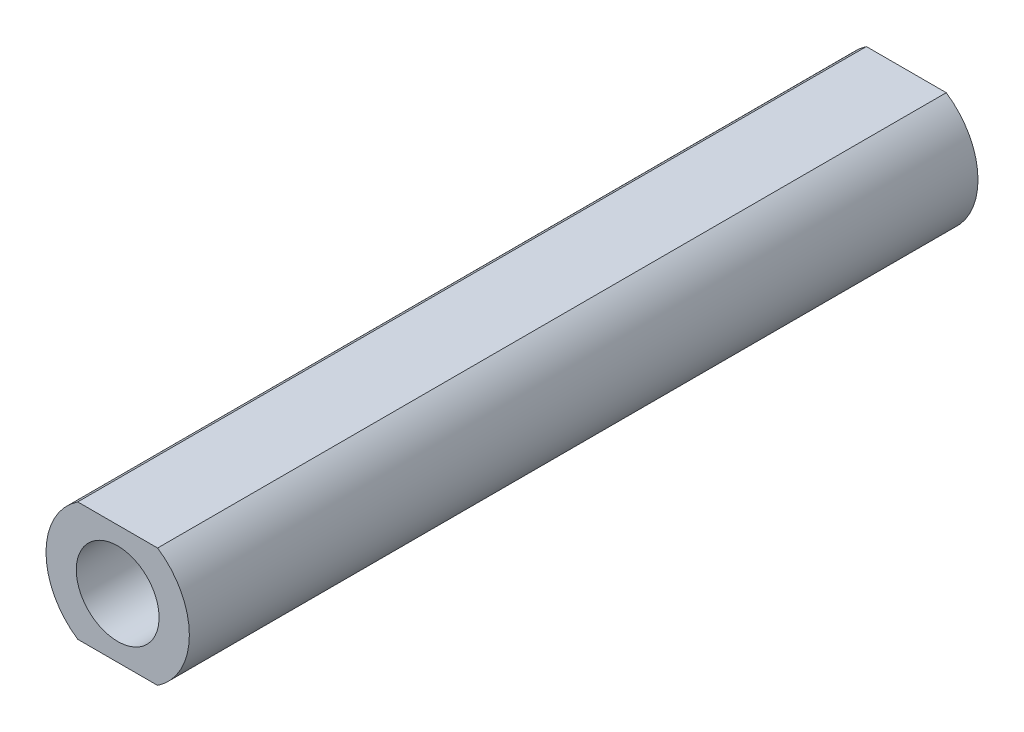
from build123d import *

# Parameters (mm, degrees)
BOSS_EXTRUDE1_DEPTH      = 76.2
F_8_0_8_DIAMETER_HOLE1_D = 8


with BuildPart() as part:
    # Sketch1 → Boss-Extrude1 (new body)
    with BuildSketch(Plane.XY):
        with BuildLine():
            Line((-3.859161178, -5.75), (3.859161178, -5.75))
            ThreePointArc((3.859161178, -5.75), (6.925, 0), (3.859161178, 5.75))
            Line((3.859161178, 5.75), (-3.859161178, 5.75))
            ThreePointArc((-3.859161178, 5.75), (-6.925, 0), (-3.859161178, -5.75))
        make_face()
    extrude(amount=BOSS_EXTRUDE1_DEPTH)

    # Ø8.0 (8) Diameter Hole1 (through all)
    with Locations(Plane(origin=(0, 0, 0), x_dir=(-1, 0, 0), z_dir=(0, 0, -1))):
        with Locations((0, 0)):
            Hole(F_8_0_8_DIAMETER_HOLE1_D / 2)


solid = part.part
